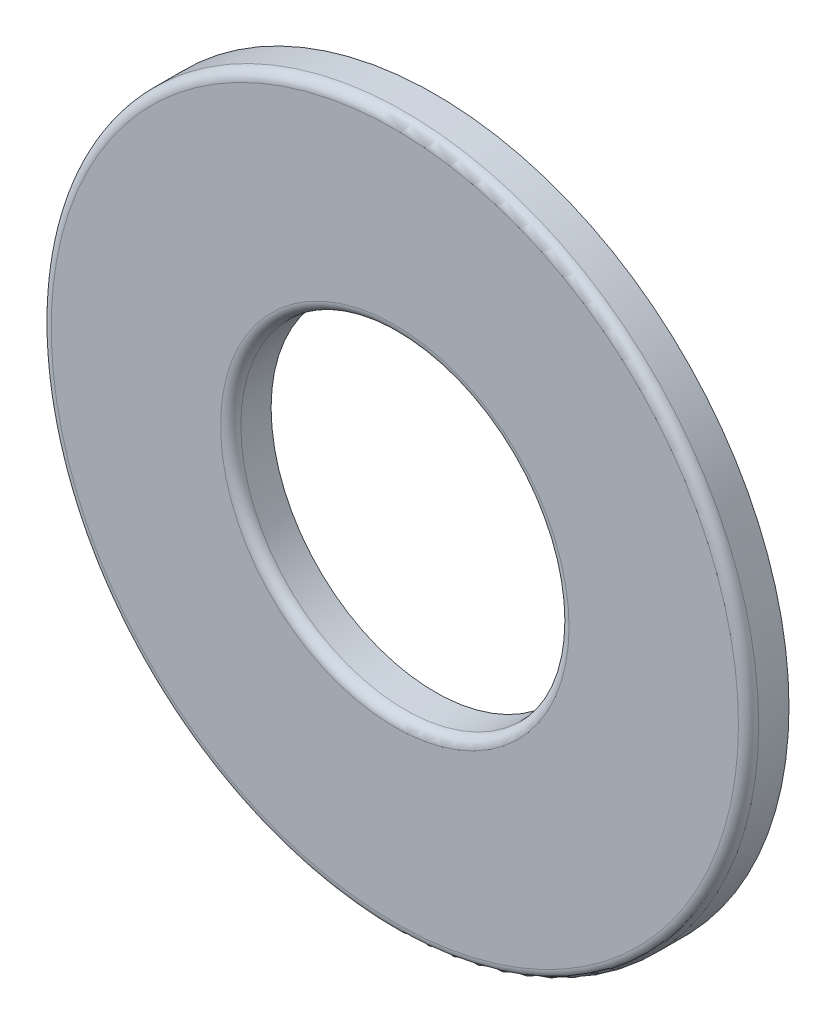
from build123d import *

# Parameters (mm, degrees)
SKETCH3_R                = 11.1125
SKETCH3_R_2              = 5.1562
BOSS_EXTRUDE1_DEPTH      = 0.635
BOSS_EXTRUDE1_DEPTH_BACK = 0.635
FILLET1_R                = 0.3175


with BuildPart() as part:
    # Sketch3 → Boss-Extrude1 (new body, two sides)
    with BuildSketch(Plane.XY) as boss_extrude1_sk:
        Circle(SKETCH3_R)
        Circle(SKETCH3_R_2, mode=Mode.SUBTRACT)
    extrude(amount=BOSS_EXTRUDE1_DEPTH)
    extrude(boss_extrude1_sk.sketch, amount=-BOSS_EXTRUDE1_DEPTH_BACK)

    # Fillet1
    fillet1_edges = [part.edges().sort_by_distance(p)[0] for p in [
        (-11.1125, 0, 0.635),
        (-5.1562, 0, 0.635),
    ]]
    fillet(fillet1_edges, radius=FILLET1_R)


solid = part.part
